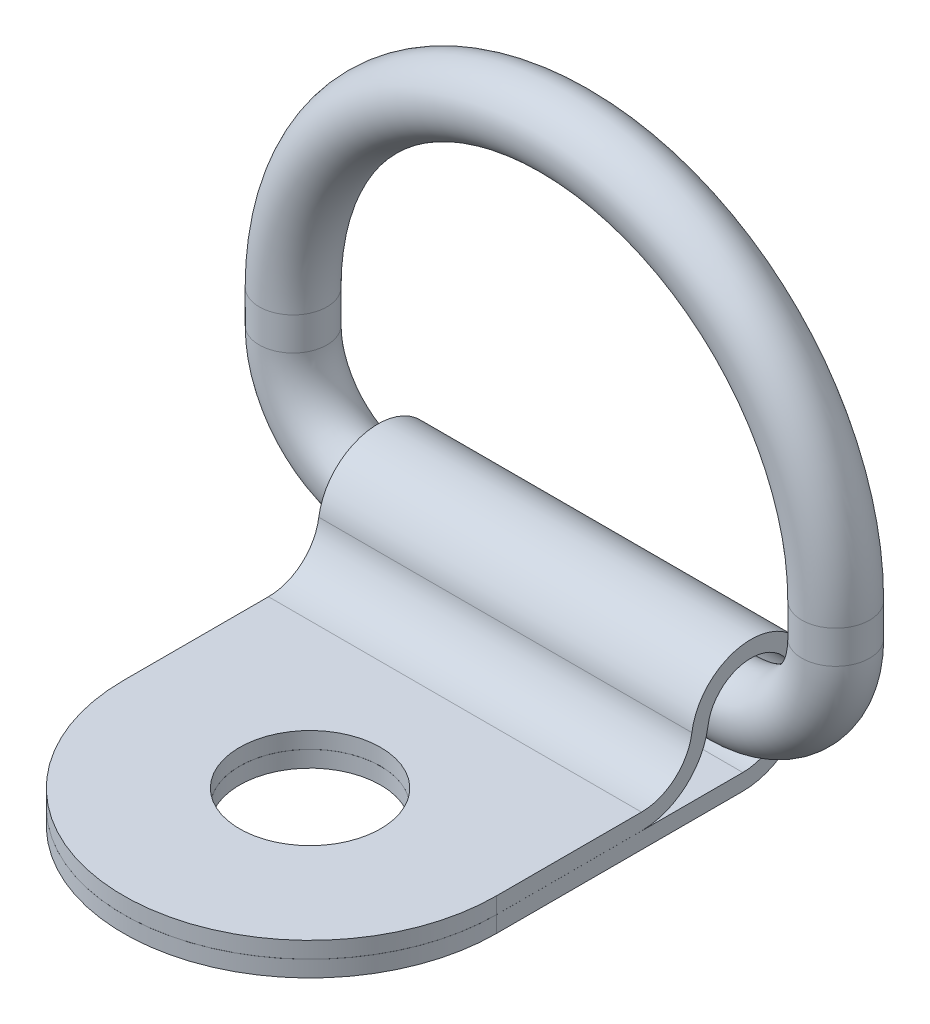
from build123d import *

# Parameters (mm, degrees)
SKETCH2_R           = 1.5875
BOSS_EXTRUDE1_DEPTH = 8.73125
SKETCH4_R           = 3.302
CUT_EXTRUDE1_DEPTH  = 24.8125001


with BuildPart() as part:
    # Sweep1: sweep along a path in Sketch1
    with BuildLine(Plane.XY) as sweep1_path:
        Line((-12.7, 6.35), (-12.7, 4.805901242))
        ThreePointArc((-12.7, 4.805901242), (-11.292384116, 1.407615884), (-7.894098758, 0))
        Line((-7.894098758, 0), (7.894098758, 0))
        ThreePointArc((7.894098758, 0), (11.292384116, 1.407615884), (12.7, 4.805901242))
        Line((12.7, 4.805901242), (12.7, 6.35))
        ThreePointArc((12.7, 6.35), (0, 19.05), (-12.7, 6.35))
    # Sketch2 → Sweep1 (sweep)
    with BuildSketch(Plane(origin=(0, 0, 0), x_dir=(0, 0, -1), z_dir=(1, 0, 0))):
        Circle(SKETCH2_R)
    sweep(path=sweep1_path.line)


with BuildPart() as body_2:
    # Sketch3 → Boss-Extrude1 (new body, symmetric)
    with BuildSketch(Plane(origin=(0, 0, 0), x_dir=(0, 0, -1), z_dir=(1, 0, 0))):
        with BuildLine():
            Line((-20.6375, -3.175), (-0.381, -3.175))
            ThreePointArc((-0.381, -3.175), (1.86406403, -2.24506403), (2.794, 0))
            ThreePointArc((2.794, 0), (0.198308481, 2.786953488), (-2.765849496, 0.395616687))
            ThreePointArc((-2.765849496, 0.395616687), (-3.563066307, -1.066271632), (-5.12310759, -1.64846))
            Line((-5.12310759, -1.64846), (-20.6375, -1.64846))
            Line((-20.6375, -1.64846), (-20.6375, -2.41046))
            Line((-20.6375, -2.41046), (-5.12310759, -2.41046))
            ThreePointArc((-5.12310759, -2.41046), (-3.063853096, -1.641971355), (-2.011526906, 0.287721227))
            ThreePointArc((-2.011526906, 0.287721227), (0.14422435, 2.026875264), (2.032, 0))
            ThreePointArc((2.032, 0), (1.325248663, -1.706248663), (-0.381, -2.413))
            Line((-0.381, -2.413), (-20.6375, -2.413))
            Line((-20.6375, -2.413), (-20.6375, -3.175))
        make_face()
    extrude(amount=BOSS_EXTRUDE1_DEPTH, both=True)

    # Sketch4 → Cut-Extrude1 (cut, through all)
    with BuildSketch(Plane.XZ.offset(3.175)):
        with Locations((0, 11.90625)):
            Circle(SKETCH4_R)
        with BuildLine():
            Line((-8.73125, 11.90625), (-8.73125, 20.6375))
            Line((-8.73125, 20.6375), (-8.73125, 21.9075))
            Line((-8.73125, 21.9075), (8.73125, 21.9075))
            Line((8.73125, 21.9075), (8.73125, 20.6375))
            Line((8.73125, 20.6375), (8.73125, 11.90625))
            ThreePointArc((8.73125, 11.90625), (0, 20.6375), (-8.73125, 11.90625))
        make_face()
    extrude(amount=-CUT_EXTRUDE1_DEPTH, mode=Mode.SUBTRACT)


solid = Compound([part.part, body_2.part])
